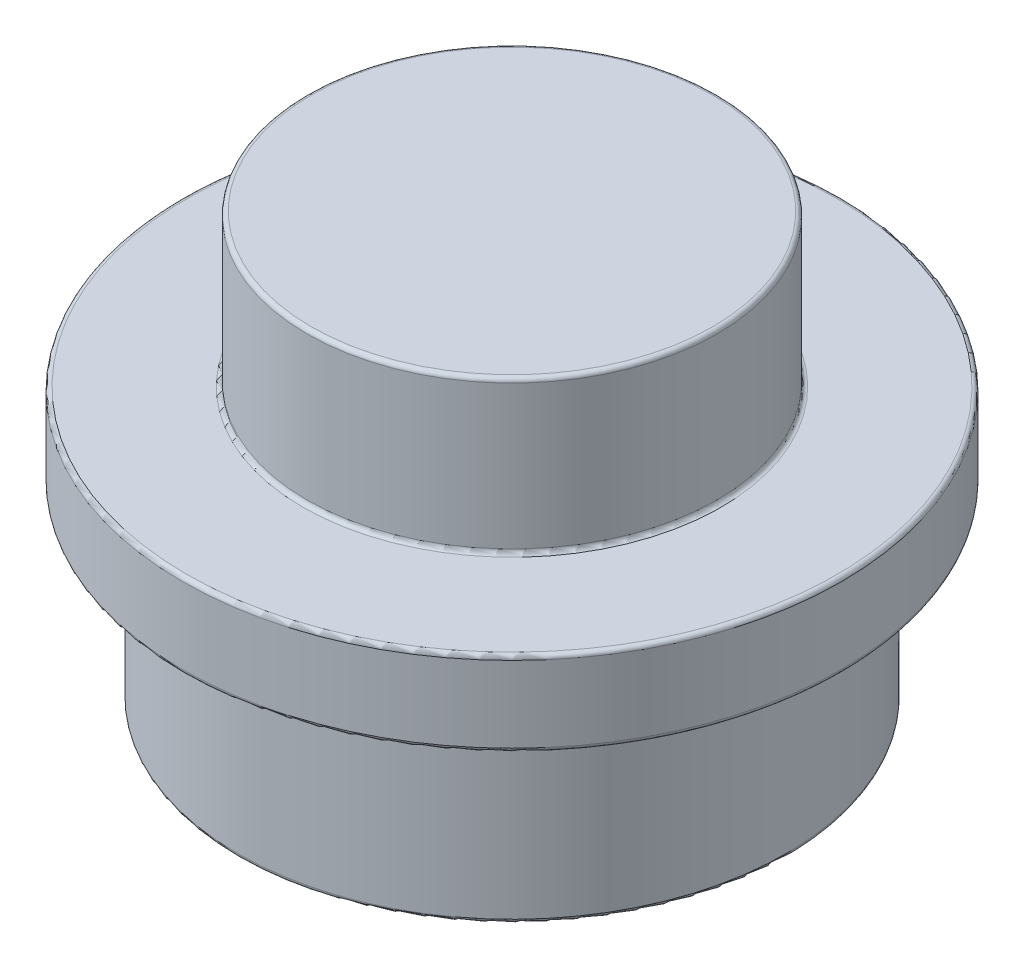
from build123d import *

# Parameters (mm, degrees)
SKETCH1_R      = 3.9
EXTRUDE1_DEPTH = 3.22
SKETCH2_R      = 2.425
EXTRUDE2_DEPTH = 1.8
SKETCH3_R      = 3.9
SKETCH3_R_2    = 3.24
EXTRUDE3_DEPTH = 2.22
SHELL1_T       = -1.55
FILLET1_R      = 0.05


with BuildPart() as part:
    # Sketch1 → Extrude1 (new body)
    with BuildSketch(Plane(origin=(0, 0, 0), x_dir=(1, 0, 0), z_dir=(0, 1, 0))):
        with Locations(Location((0, 0, 0), (0, 0, 90))):
            Circle(SKETCH1_R)
    extrude(amount=EXTRUDE1_DEPTH)

    # Sketch2 → Extrude2 (add)
    with BuildSketch(Plane(origin=(0, 3.22, 0), x_dir=(1, 0, 0), z_dir=(0, 1, 0))):
        with Locations(Location((0, 0, 0), (0, 0, 270))):
            Circle(SKETCH2_R)
    extrude(amount=EXTRUDE2_DEPTH)

    # Sketch3 → Extrude3 (cut)
    with BuildSketch(Plane.XZ):
        with Locations(Location((0, 0, 0), (0, 0, 270))):
            Circle(SKETCH3_R)
        with Locations(Location((0, 0, 0), (0, 0, 270))):
            Circle(SKETCH3_R_2, mode=Mode.SUBTRACT)
    extrude(amount=-EXTRUDE3_DEPTH, mode=Mode.SUBTRACT)

    # Shell1
    shell1_openings = [part.faces().sort_by_distance(p)[0] for p in [
        (0, 0, 0),
    ]]
    offset(amount=SHELL1_T, openings=shell1_openings, kind=Kind.INTERSECTION)

    # Fillet1
    fillet1_edges = [part.edges().sort_by_distance(p)[0] for p in [
        (0, 2.22, 3.9),
        (0, 0, 3.24),
        (0, 2.22, 3.24),
        (0, 1.67, 1.69),
        (0, 1.67, -0.875),
        (0, 3.47, -0.875),
        (0, 0, 1.69),
        (0, 3.22, 3.9),
        (0, 3.22, -2.425),
        (0, 5.02, -2.425),
    ]]
    fillet(fillet1_edges, radius=FILLET1_R)


solid = part.part
